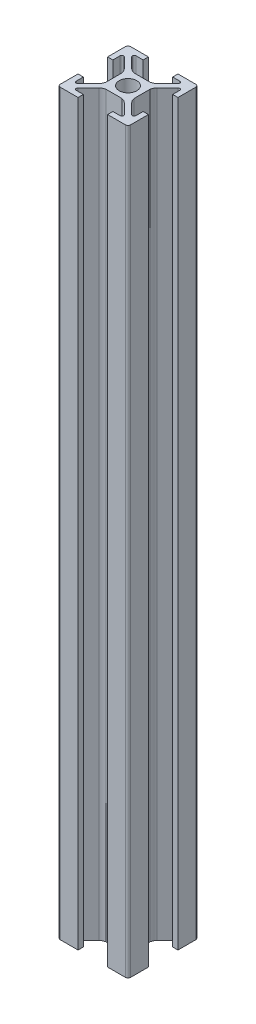
from build123d import *

# Parameters (mm, degrees)
SKETCH1_R           = 2.5
BOSS_EXTRUDE1_DEPTH = 210


with BuildPart() as part:
    # Sketch1 → Boss-Extrude1 (new body)
    with BuildSketch(Plane(origin=(0, 0, 0), x_dir=(1, 0, 0), z_dir=(0, 1, 0))):
        with BuildLine():
            Line((-3.610984523, 4.671644695), (-6.585786438, 7.646446609))
            ThreePointArc((-6.585786438, 7.646446609), (-6.694172813, 8.191341716), (-6.232233047, 8.5))
            Line((-6.232233047, 8.5), (-4.2, 8.5))
            Line((-4.2, 8.5), (-4.2, 10))
            Line((-4.2, 10), (-9.25, 10))
            ThreePointArc((-9.25, 10), (-9.780330086, 9.780330086), (-10, 9.25))
            Line((-10, 9.25), (-10, 4.2))
            Line((-10, 4.2), (-8.5, 4.2))
            Line((-8.5, 4.2), (-8.5, 6.232233047))
            ThreePointArc((-8.5, 6.232233047), (-8.191341716, 6.694172813), (-7.646446609, 6.585786438))
            Line((-7.646446609, 6.585786438), (-4.671644695, 3.610984523))
            ThreePointArc((-4.671644695, 3.610984523), (-4.244383234, 2.985253206), (-4, 2.268058063))
            Line((-4, 2.268058063), (-4, -2.268058063))
            ThreePointArc((-4, -2.268058063), (-4.244383234, -2.985253206), (-4.671644695, -3.610984523))
            Line((-4.671644695, -3.610984523), (-7.646446609, -6.585786438))
            ThreePointArc((-7.646446609, -6.585786438), (-8.191341716, -6.694172813), (-8.5, -6.232233047))
            Line((-8.5, -6.232233047), (-8.5, -4.2))
            Line((-8.5, -4.2), (-10, -4.2))
            Line((-10, -4.2), (-10, -9.25))
            ThreePointArc((-10, -9.25), (-9.780330086, -9.780330086), (-9.25, -10))
            Line((-9.25, -10), (-4.2, -10))
            Line((-4.2, -10), (-4.2, -8.5))
            Line((-4.2, -8.5), (-6.232233047, -8.5))
            ThreePointArc((-6.232233047, -8.5), (-6.694172813, -8.191341716), (-6.585786438, -7.646446609))
            Line((-6.585786438, -7.646446609), (-3.610984523, -4.671644695))
            ThreePointArc((-3.610984523, -4.671644695), (-2.985253206, -4.244383234), (-2.268058063, -4))
            Line((-2.268058063, -4), (2.268058063, -4))
            ThreePointArc((2.268058063, -4), (2.985253206, -4.244383234), (3.610984523, -4.671644695))
            Line((3.610984523, -4.671644695), (6.585786438, -7.646446609))
            ThreePointArc((6.585786438, -7.646446609), (6.694172813, -8.191341716), (6.232233047, -8.5))
            Line((6.232233047, -8.5), (4.2, -8.5))
            Line((4.2, -8.5), (4.2, -10))
            Line((4.2, -10), (9.25, -10))
            ThreePointArc((9.25, -10), (9.780330086, -9.780330086), (10, -9.25))
            Line((10, -9.25), (10, -4.2))
            Line((10, -4.2), (8.5, -4.2))
            Line((8.5, -4.2), (8.5, -6.232233047))
            ThreePointArc((8.5, -6.232233047), (8.191341716, -6.694172813), (7.646446609, -6.585786438))
            Line((7.646446609, -6.585786438), (4.671644695, -3.610984523))
            ThreePointArc((4.671644695, -3.610984523), (4.244383234, -2.985253206), (4, -2.268058063))
            Line((4, -2.268058063), (4, 2.268058063))
            ThreePointArc((4, 2.268058063), (4.244383234, 2.985253206), (4.671644695, 3.610984523))
            Line((4.671644695, 3.610984523), (7.646446609, 6.585786438))
            ThreePointArc((7.646446609, 6.585786438), (8.191341716, 6.694172813), (8.5, 6.232233047))
            Line((8.5, 6.232233047), (8.5, 4.2))
            Line((8.5, 4.2), (10, 4.2))
            Line((10, 4.2), (10, 9.25))
            ThreePointArc((10, 9.25), (9.780330086, 9.780330086), (9.25, 10))
            Line((9.25, 10), (4.2, 10))
            Line((4.2, 10), (4.2, 8.5))
            Line((4.2, 8.5), (6.232233047, 8.5))
            ThreePointArc((6.232233047, 8.5), (6.694172813, 8.191341716), (6.585786438, 7.646446609))
            Line((6.585786438, 7.646446609), (3.610984523, 4.671644695))
            ThreePointArc((3.610984523, 4.671644695), (2.985253206, 4.244383234), (2.268058063, 4))
            Line((2.268058063, 4), (-2.268058063, 4))
            ThreePointArc((-2.268058063, 4), (-2.985253206, 4.244383234), (-3.610984523, 4.671644695))
        make_face()
        Circle(SKETCH1_R, mode=Mode.SUBTRACT)
    extrude(amount=BOSS_EXTRUDE1_DEPTH)


solid = part.part
